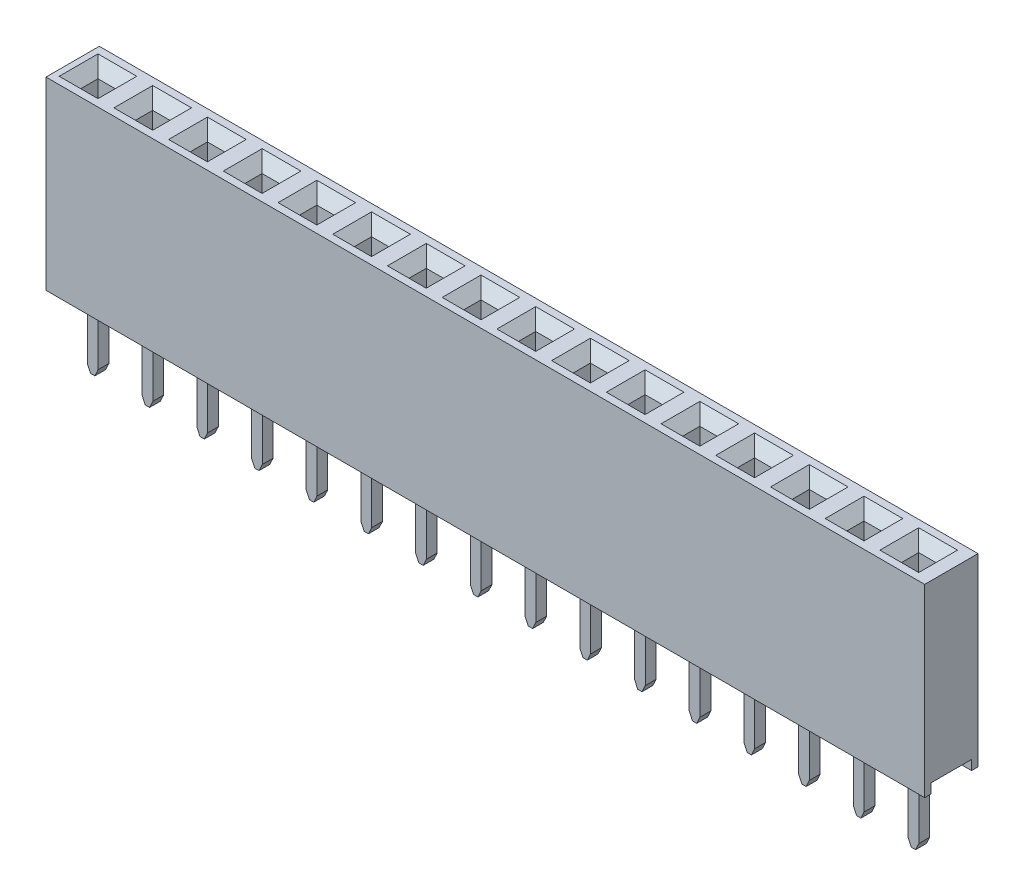
from build123d import *

# Parameters (mm, degrees)
SKETCH1_W                  = 40.79
SKETCH1_H                  = 8.575
BOSS_EXTRUDE1_DEPTH        = 1.2375
SKETCH2_W                  = 1.875
SKETCH2_H                  = 0.447874384
CUT_EXTRUDE1_DEPTH         = 50
SKETCH4_W                  = 0.8
SKETCH4_H                  = 0.8
CUT_EXTRUDE2_DEPTH         = 1.5
CHAMFER1_SIZE              = 0.5
SKETCH5_W                  = 1.8
SKETCH5_H                  = 1.8
CUT_EXTRUDE3_DEPTH         = 3
BOSS_EXTRUDE4_DEPTH        = 0.85
BOSS_EXTRUDE5_DEPTH        = 0.25
LPATTERN1_COUNT            = 16
LPATTERN1_PITCH            = 2.54
CHAMFER1_OF_LPATTERN1_SIZE = 0.5


with BuildPart() as part:
    # Sketch1 → Boss-Extrude1 (new body, symmetric)
    with BuildSketch(Plane.XY):
        Rectangle(SKETCH1_W, SKETCH1_H)
    extrude(amount=BOSS_EXTRUDE1_DEPTH, both=True)

    # Sketch2 → Cut-Extrude1 (cut, symmetric)
    with BuildSketch(Plane(origin=(0, 0, 0), x_dir=(0, 0, -1), z_dir=(1, 0, 0))):
        with Locations((0, -4.063562808)):
            Rectangle(SKETCH2_W, SKETCH2_H)
    extrude(amount=CUT_EXTRUDE1_DEPTH, both=True, mode=Mode.SUBTRACT)

    # Sketch4 → Cut-Extrude2 (cut)
    with BuildSketch(Plane(origin=(0, 4.2875, 0), x_dir=(1, 0, 0), z_dir=(0, 1, 0))):
        with Locations((-19.22, 0)):
            Rectangle(SKETCH4_W, SKETCH4_H)
    cut_extrude2 = extrude(amount=-CUT_EXTRUDE2_DEPTH, mode=Mode.SUBTRACT)

    # Chamfer1
    chamfer1_edges = [part.edges().sort_by_distance(p)[0] for p in [
        (-18.82, 4.2875, 0),
        (-19.22, 4.2875, -0.4),
        (-19.62, 4.2875, 0),
        (-19.22, 4.2875, 0.4),
    ]]
    chamfer(chamfer1_edges, length=CHAMFER1_SIZE)

    # Sketch5 → Cut-Extrude3 (cut, symmetric)
    with BuildSketch(Plane(origin=(0, 0, 0), x_dir=(1, 0, 0), z_dir=(0, 1, 0))):
        with Locations((-19.22, 0)):
            Rectangle(SKETCH5_W, SKETCH5_H)
    cut_extrude3 = extrude(amount=CUT_EXTRUDE3_DEPTH, both=True, mode=Mode.SUBTRACT)

    # Sketch9 → Boss-Extrude4 (add, symmetric)
    with BuildSketch(Plane.XY):
        with BuildLine():
            Line((-18.32, -1.258559541), (-18.348014959, -1.140581312))
            Line((-18.348014959, -1.140581312), (-18.798030642, 1.57061977))
            ThreePointArc((-18.798030642, 1.57061977), (-19.051507644, 1.635939005), (-18.929425263, 1.404394008))
            Line((-18.929425263, 1.404394008), (-18.702200943, -1.906588934))
            ThreePointArc((-18.702200943, -1.906588934), (-18.852081635, -2.25095927), (-19.22, -2.326399486))
            ThreePointArc((-19.22, -2.326399486), (-19.587918365, -2.25095927), (-19.737799057, -1.906588934))
            Line((-19.737799057, -1.906588934), (-19.510574737, 1.404394008))
            ThreePointArc((-19.510574737, 1.404394008), (-19.388492356, 1.635939005), (-19.641969358, 1.57061977))
            Line((-19.641969358, 1.57061977), (-20.091985041, -1.140581312))
            Line((-20.091985041, -1.140581312), (-20.12, -1.258559541))
            Line((-20.12, -1.258559541), (-20.12, -2.610217055))
            Line((-20.12, -2.610217055), (-19.847962444, -2.970231597))
            Line((-19.847962444, -2.970231597), (-18.592037556, -2.970231597))
            Line((-18.592037556, -2.970231597), (-18.32, -2.610217055))
            Line((-18.32, -2.610217055), (-18.32, -1.258559541))
        make_face()
    boss_extrude4 = extrude(amount=BOSS_EXTRUDE4_DEPTH, both=True)

    # Sketch9_3 → Boss-Extrude5 (add, symmetric)
    with BuildSketch(Plane.XY):
        Polygon((-18.963441334, -7.25699109), (-18.963441334, -2.970231597), (-19.463441334, -2.970231597), (-19.463441334, -7.25699109), (-19.313441334, -7.578667128), (-19.113441334, -7.578667128), align=None)
    boss_extrude5 = extrude(amount=BOSS_EXTRUDE5_DEPTH, both=True)

    # LPattern1: Cut-Extrude2, Cut-Extrude3, Boss-Extrude4, Boss-Extrude5 ×16
    with Locations(*[(i * LPATTERN1_PITCH, 0, 0) for i in range(1, LPATTERN1_COUNT)]):
        add(cut_extrude2, mode=Mode.SUBTRACT)
        add(cut_extrude3, mode=Mode.SUBTRACT)
        add(boss_extrude4)
        add(boss_extrude5)

    # Chamfer1 of LPattern1
    chamfer1_of_lpattern1_edges = [part.edges().sort_by_distance(p)[0] for p in [
        (-16.28, 4.2875, 0),
        (-16.68, 4.2875, -0.4),
        (-17.08, 4.2875, 0),
        (-16.68, 4.2875, 0.4),
        (-13.74, 4.2875, 0),
        (-14.14, 4.2875, -0.4),
        (-14.54, 4.2875, 0),
        (-14.14, 4.2875, 0.4),
        (-11.2, 4.2875, 0),
        (-11.6, 4.2875, -0.4),
        (-12, 4.2875, 0),
        (-11.6, 4.2875, 0.4),
        (-8.66, 4.2875, 0),
        (-9.06, 4.2875, -0.4),
        (-9.46, 4.2875, 0),
        (-9.06, 4.2875, 0.4),
        (-6.12, 4.2875, 0),
        (-6.52, 4.2875, -0.4),
        (-6.92, 4.2875, 0),
        (-6.52, 4.2875, 0.4),
        (-3.58, 4.2875, 0),
        (-3.98, 4.2875, -0.4),
        (-4.38, 4.2875, 0),
        (-3.98, 4.2875, 0.4),
        (-1.04, 4.2875, 0),
        (-1.44, 4.2875, -0.4),
        (-1.84, 4.2875, 0),
        (-1.44, 4.2875, 0.4),
        (1.5, 4.2875, 0),
        (1.1, 4.2875, -0.4),
        (0.7, 4.2875, 0),
        (1.1, 4.2875, 0.4),
        (4.04, 4.2875, 0),
        (3.64, 4.2875, -0.4),
        (3.24, 4.2875, 0),
        (3.64, 4.2875, 0.4),
        (6.58, 4.2875, 0),
        (6.18, 4.2875, -0.4),
        (5.78, 4.2875, 0),
        (6.18, 4.2875, 0.4),
        (9.12, 4.2875, 0),
        (8.72, 4.2875, -0.4),
        (8.32, 4.2875, 0),
        (8.72, 4.2875, 0.4),
        (11.66, 4.2875, 0),
        (11.26, 4.2875, -0.4),
        (10.86, 4.2875, 0),
        (11.26, 4.2875, 0.4),
        (14.2, 4.2875, 0),
        (13.8, 4.2875, -0.4),
        (13.4, 4.2875, 0),
        (13.8, 4.2875, 0.4),
        (16.74, 4.2875, 0),
        (16.34, 4.2875, -0.4),
        (15.94, 4.2875, 0),
        (16.34, 4.2875, 0.4),
        (19.28, 4.2875, 0),
        (18.88, 4.2875, -0.4),
        (18.48, 4.2875, 0),
        (18.88, 4.2875, 0.4),
    ]]
    chamfer(chamfer1_of_lpattern1_edges, length=CHAMFER1_OF_LPATTERN1_SIZE)


solid = part.part
